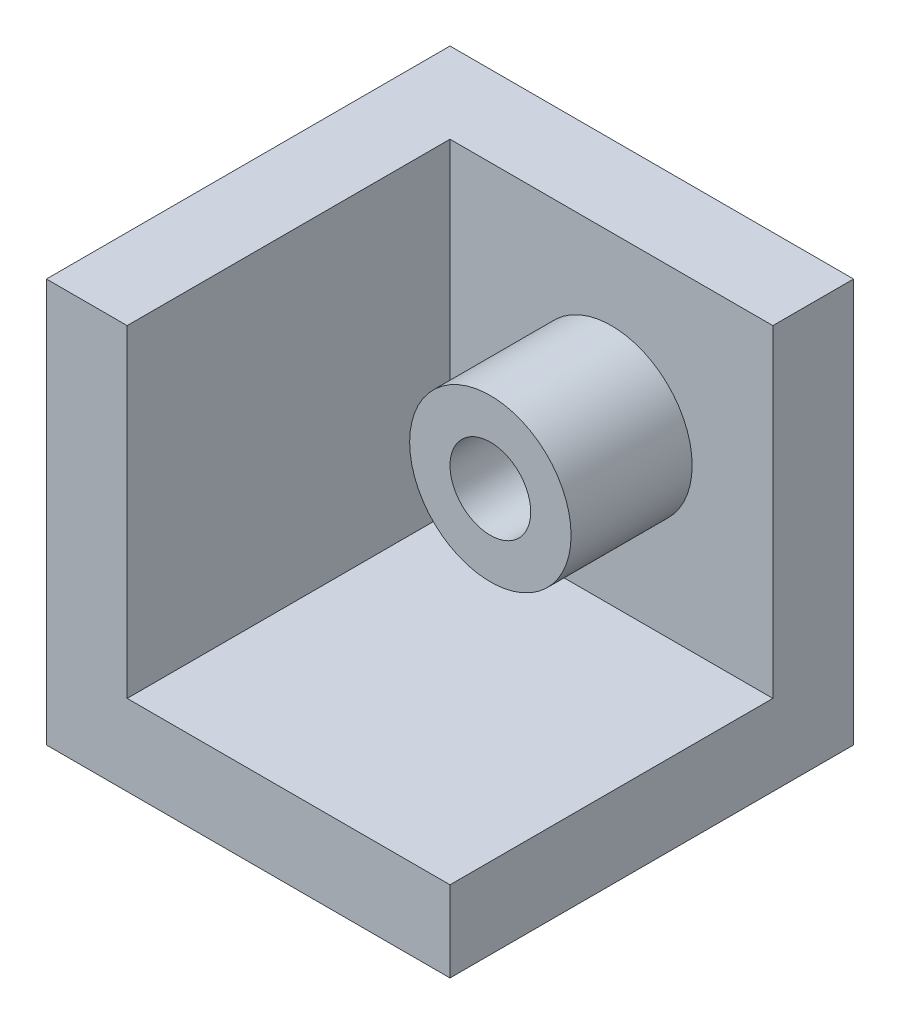
from build123d import *

# Parameters (mm, degrees)
SKETCH1_W           = 100
SKETCH1_H           = 100
BOSS_EXTRUDE1_DEPTH = 100
SKETCH2_W           = 80
SKETCH2_H           = 80
CUT_EXTRUDE1_DEPTH  = 80
SKETCH3_R           = 10
CUT_EXTRUDE2_DEPTH  = 20
BOSS_EXTRUDE3_START = 30
SKETCH3_5_R         = 20
SKETCH3_5_R_2       = 10
BOSS_EXTRUDE3_DEPTH = 30


with BuildPart() as part:
    # Sketch1 → Boss-Extrude1 (new body)
    with BuildSketch(Plane.XY):
        with Locations((50, 50)):
            Rectangle(SKETCH1_W, SKETCH1_H)
    extrude(amount=BOSS_EXTRUDE1_DEPTH)

    # Sketch2 → Cut-Extrude1 (cut)
    with BuildSketch(Plane(origin=(0, 100, 0), x_dir=(1, 0, 0), z_dir=(0, 1, 0))):
        with Locations((60, -60)):
            Rectangle(SKETCH2_W, SKETCH2_H)
    extrude(amount=-CUT_EXTRUDE1_DEPTH, mode=Mode.SUBTRACT)

    # Sketch3 → Cut-Extrude2 (cut)
    with BuildSketch(Plane.XY.offset(20)):
        with Locations((60, 60)):
            Circle(SKETCH3_R)
    extrude(amount=-CUT_EXTRUDE2_DEPTH, mode=Mode.SUBTRACT)

    # Sketch3_5 → Boss-Extrude3 (add)
    with BuildSketch(Plane.XY.offset(20).offset(BOSS_EXTRUDE3_START)):
        with Locations((60, 60)):
            Circle(SKETCH3_5_R)
        with Locations((60, 60)):
            Circle(SKETCH3_5_R_2, mode=Mode.SUBTRACT)
    extrude(amount=-BOSS_EXTRUDE3_DEPTH)


solid = part.part
